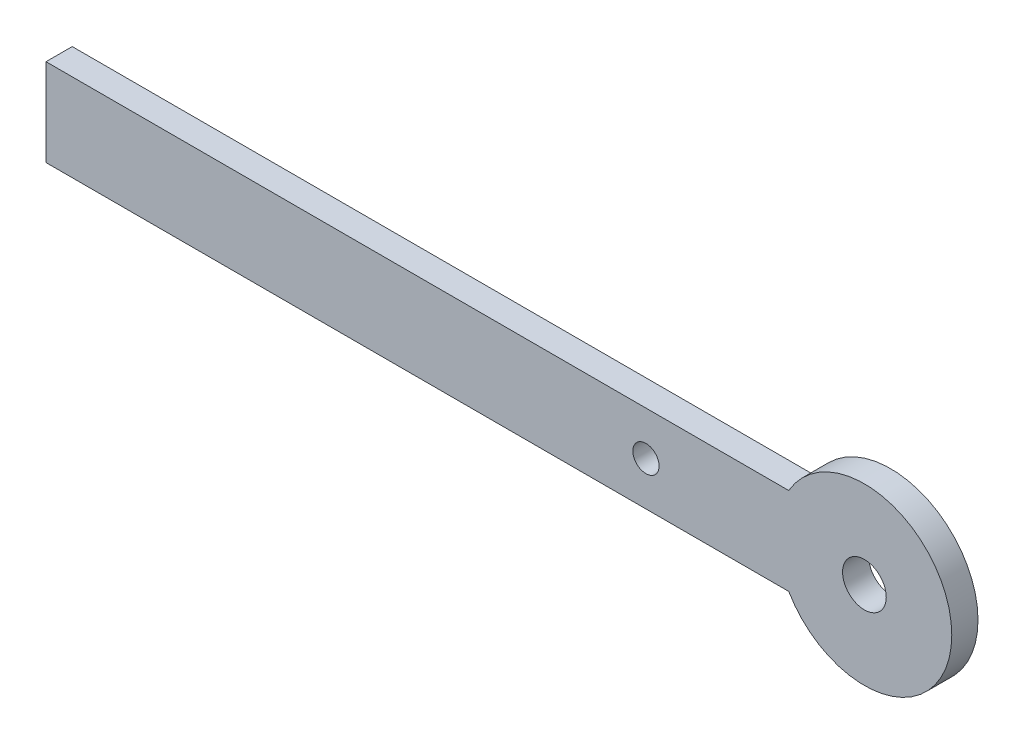
from build123d import *

# Parameters (mm, degrees)
SKETCH1_R           = 2.5
BOSS_EXTRUDE1_DEPTH = 3
SKETCH2_R           = 1.5
CUT_EXTRUDE1_DEPTH  = 10


with BuildPart() as part:
    # Sketch1 → Boss-Extrude1 (new body)
    with BuildSketch(Plane.XY):
        with BuildLine():
            Line((-93.660254038, 5), (-8.660254038, 5))
            ThreePointArc((-8.660254038, 5), (10, 0), (-8.660254038, -5))
            Line((-8.660254038, -5), (-93.660254038, -5))
            Line((-93.660254038, -5), (-93.660254038, 5))
        make_face()
        Circle(SKETCH1_R, mode=Mode.SUBTRACT)
    extrude(amount=BOSS_EXTRUDE1_DEPTH)

    # Sketch2 → Cut-Extrude1 (cut)
    with BuildSketch(Plane(origin=(0, 0, 0), x_dir=(-1, 0, 0), z_dir=(0, 0, -1))):
        with Locations((25, 0)):
            Circle(SKETCH2_R)
    extrude(amount=-CUT_EXTRUDE1_DEPTH, mode=Mode.SUBTRACT)


solid = part.part
